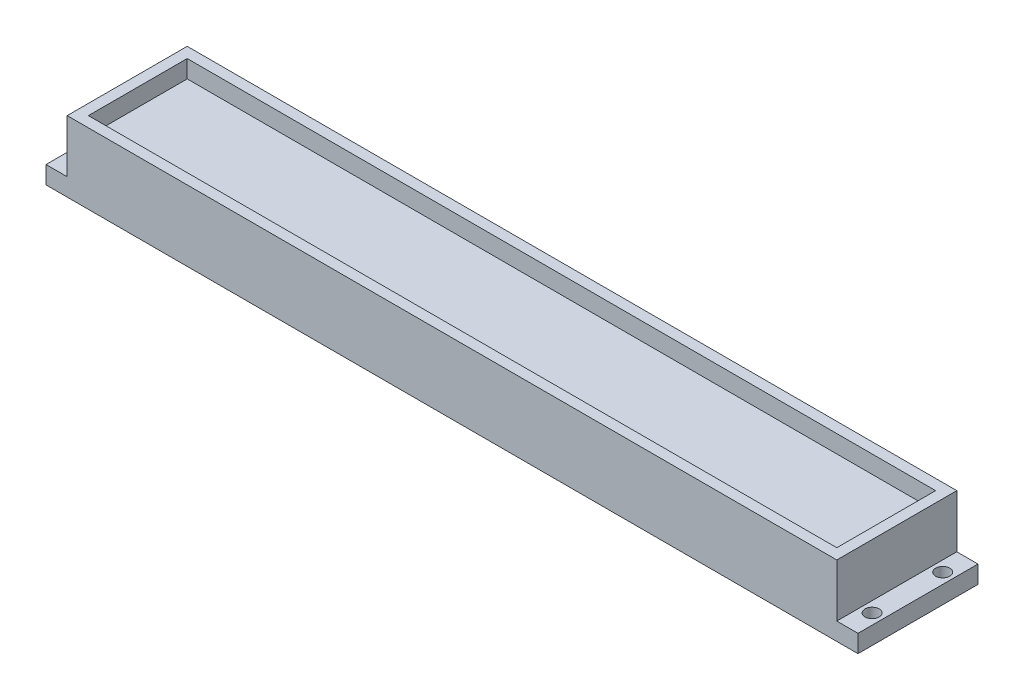
from build123d import *

# Parameters (mm, degrees)
BOSS_EXTRUDE1_DEPTH = 34
BOSS_EXTRUDE2_REACH = 22
SKETCH2_W           = 212
SKETCH2_H           = 3
CUT_EXTRUDE1_REACH  = 7
SKETCH3_R           = 2


with BuildPart() as part:
    # Sketch1 → Boss-Extrude1 (new body)
    with BuildSketch(Plane.XY):
        Polygon((0, 0), (230, 0), (230, 5), (224, 5), (224, 20), (221, 20), (221, 15), (9, 15), (9, 20), (6, 20), (6, 5), (0, 5), align=None)
    extrude(amount=BOSS_EXTRUDE1_DEPTH)

    # Sketch2 → Boss-Extrude2 (add, up to next)
    with BuildSketch(Plane(origin=(0, 20, 0), x_dir=(1, 0, 0), z_dir=(0, 1, 0)), mode=Mode.PRIVATE) as boss_extrude2_sk1:
        with Locations((115, -1.5)):
            Rectangle(SKETCH2_W, SKETCH2_H)
    boss_extrude2_tool1 = extrude(boss_extrude2_sk1.sketch, amount=-BOSS_EXTRUDE2_REACH, mode=Mode.PRIVATE) - part.part
    add(boss_extrude2_tool1.solids().sort_by_distance((115, 20, 1.5))[0])
    # Sketch2 → Boss-Extrude2 (add, up to next)
    with BuildSketch(Plane(origin=(0, 20, 0), x_dir=(1, 0, 0), z_dir=(0, 1, 0)), mode=Mode.PRIVATE) as boss_extrude2_sk2:
        with Locations((115, -32.5)):
            Rectangle(SKETCH2_W, SKETCH2_H)
    boss_extrude2_tool2 = extrude(boss_extrude2_sk2.sketch, amount=-BOSS_EXTRUDE2_REACH, mode=Mode.PRIVATE) - part.part
    add(boss_extrude2_tool2.solids().sort_by_distance((115, 20, 32.5))[0])

    # Sketch3 → Cut-Extrude1 (cut, up to next)
    with BuildSketch(Plane(origin=(0, 5, 0), x_dir=(1, 0, 0), z_dir=(0, 1, 0)), mode=Mode.PRIVATE) as cut_extrude1_sk1:
        with Locations(Location((3, -7, 0), (0, 0, 270))):  # turned: the seam where the file's is
            Circle(SKETCH3_R)
    cut_extrude1_tool1 = extrude(cut_extrude1_sk1.sketch, amount=-CUT_EXTRUDE1_REACH, mode=Mode.PRIVATE) & part.part
    add(cut_extrude1_tool1.solids().sort_by_distance((3, 5, 7))[0], mode=Mode.SUBTRACT)
    # Sketch3 → Cut-Extrude1 (cut, up to next)
    with BuildSketch(Plane(origin=(0, 5, 0), x_dir=(1, 0, 0), z_dir=(0, 1, 0)), mode=Mode.PRIVATE) as cut_extrude1_sk2:
        with Locations(Location((3, -27, 0), (0, 0, 270))):  # turned: the seam where the file's is
            Circle(SKETCH3_R)
    cut_extrude1_tool2 = extrude(cut_extrude1_sk2.sketch, amount=-CUT_EXTRUDE1_REACH, mode=Mode.PRIVATE) & part.part
    add(cut_extrude1_tool2.solids().sort_by_distance((3, 5, 27))[0], mode=Mode.SUBTRACT)
    # Sketch3 → Cut-Extrude1 (cut, up to next)
    with BuildSketch(Plane(origin=(0, 5, 0), x_dir=(1, 0, 0), z_dir=(0, 1, 0)), mode=Mode.PRIVATE) as cut_extrude1_sk3:
        with Locations(Location((227, -27, 0), (0, 0, 270))):  # turned: the seam where the file's is
            Circle(SKETCH3_R)
    cut_extrude1_tool3 = extrude(cut_extrude1_sk3.sketch, amount=-CUT_EXTRUDE1_REACH, mode=Mode.PRIVATE) & part.part
    add(cut_extrude1_tool3.solids().sort_by_distance((227, 5, 27))[0], mode=Mode.SUBTRACT)
    # Sketch3 → Cut-Extrude1 (cut, up to next)
    with BuildSketch(Plane(origin=(0, 5, 0), x_dir=(1, 0, 0), z_dir=(0, 1, 0)), mode=Mode.PRIVATE) as cut_extrude1_sk4:
        with Locations(Location((227, -7, 0), (0, 0, 270))):  # turned: the seam where the file's is
            Circle(SKETCH3_R)
    cut_extrude1_tool4 = extrude(cut_extrude1_sk4.sketch, amount=-CUT_EXTRUDE1_REACH, mode=Mode.PRIVATE) & part.part
    add(cut_extrude1_tool4.solids().sort_by_distance((227, 5, 7))[0], mode=Mode.SUBTRACT)


solid = part.part
